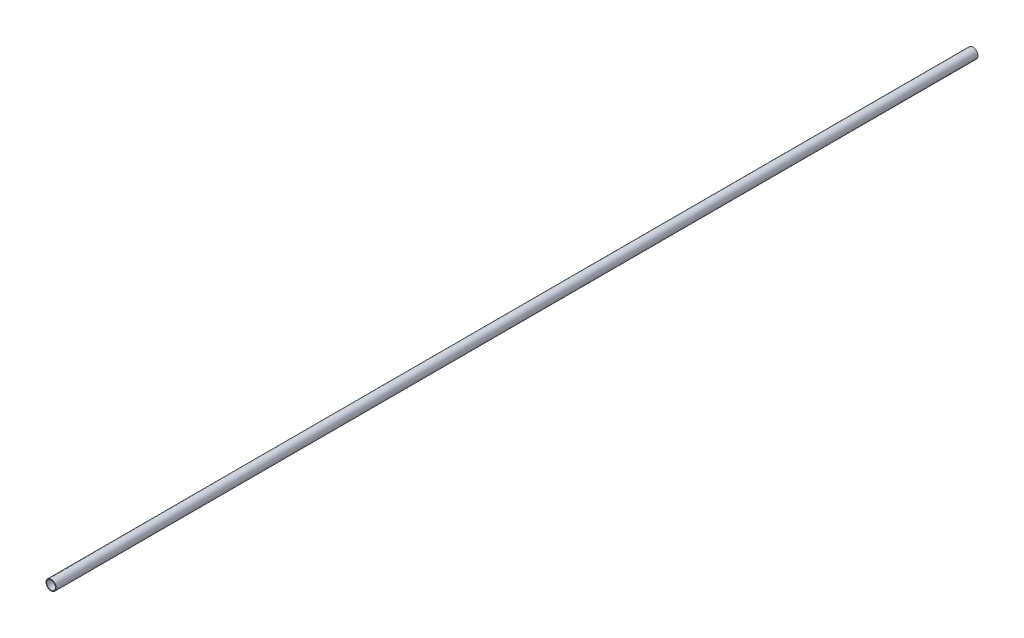
from build123d import *

# Parameters (mm, degrees)
PIPESKETCH_R    = 30.226
PIPESKETCH_R_2  = 26.3144
EXTRUSION_DEPTH = 5486.4


with BuildPart() as part:
    # PipeSketch → Extrusion (new body)
    with BuildSketch(Plane.XY):
        Circle(PIPESKETCH_R)
        Circle(PIPESKETCH_R_2, mode=Mode.SUBTRACT)
    extrude(amount=EXTRUSION_DEPTH)


solid = part.part
